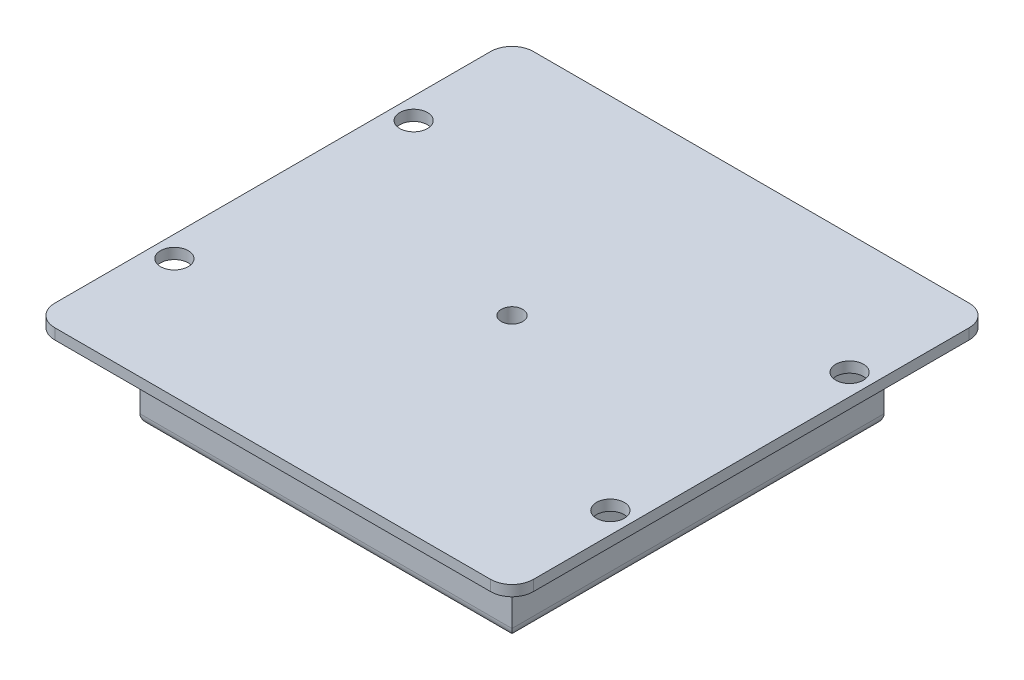
from build123d import *

# Parameters (mm, degrees)
SKETCH1_W                   = 114.3
SKETCH1_H                   = 114.3
BOSS_EXTRUDE1_DEPTH         = 2.54
SKETCH2_W                   = 88.9
SKETCH2_H                   = 88.9
BOSS_EXTRUDE2_DEPTH         = 20.32
G_0_261_DIAMETER_HOLE1_D    = 6.6294
FILLET1_R                   = 2.54
FILLET2_R                   = 5.08
BOSS_EXTRUDE3_DEPTH         = 12.7
SKETCH8_R                   = 3.81
CUT_EXTRUDE1_DEPTH          = 12.7
F_1_4_20_TAPPED_HOLE1_D     = 5.1054
F_1_4_20_TAPPED_HOLE1_DEPTH = 16.51
F_1_4_20_TAPPED_HOLE1_TIP   = 1.533816902


with BuildPart() as part:
    # Sketch1 → Boss-Extrude1 (new body)
    with BuildSketch(Plane(origin=(0, 0, 0), x_dir=(1, 0, 0), z_dir=(0, 1, 0))):
        Rectangle(SKETCH1_W, SKETCH1_H)
    extrude(amount=BOSS_EXTRUDE1_DEPTH)

    # Sketch2 → Boss-Extrude2 (add)
    with BuildSketch(Plane.XZ):
        Rectangle(SKETCH2_W, SKETCH2_H)
    extrude(amount=BOSS_EXTRUDE2_DEPTH)

    # G (0.261) Diameter Hole1 (through all)
    with Locations(Plane(origin=(0, 0, 0), x_dir=(-1, 0, 0), z_dir=(0, -1, 0))):
        with Locations((52.07, -28.575), (52.07, 28.575), (-52.07, -28.575), (-52.07, 28.575)):
            Hole(G_0_261_DIAMETER_HOLE1_D / 2)

    # Fillet1
    fillet1_edges = [part.edges().sort_by_distance(p)[0] for p in [
        (44.45, -20.32, 0),
        (0, -20.32, 44.45),
        (-44.45, -20.32, 0),
        (0, -20.32, -44.45),
    ]]
    fillet(fillet1_edges, radius=FILLET1_R)

    # Fillet2
    fillet2_edges = [part.edges().sort_by_distance(p)[0] for p in [
        (-57.15, 1.27, -57.15),
        (57.15, 1.27, -57.15),
        (57.15, 1.27, 57.15),
        (-57.15, 1.27, 57.15),
    ]]
    fillet(fillet2_edges, radius=FILLET2_R)

    # Sketch5 → Boss-Extrude3 (add)
    with BuildSketch(Plane.ZY.offset(44.45)):
        with BuildLine():
            ThreePointArc((-6.35, -8.89), (0, -15.24), (6.35, -8.89))
            Line((6.35, -8.89), (-6.35, -8.89))
        make_face()
        with BuildLine():
            Line((-6.35, -8.89), (6.35, -8.89))
            ThreePointArc((6.35, -8.89), (0, -2.54), (-6.35, -8.89))
        make_face()
        with BuildLine():
            ThreePointArc((-6.35, -8.89), (0, -2.54), (6.35, -8.89))
            Line((6.35, -8.89), (6.35, 0))
            Line((6.35, 0), (-6.35, 0))
            Line((-6.35, 0), (-6.35, -8.89))
        make_face()
    extrude(amount=BOSS_EXTRUDE3_DEPTH)

    # Sketch8 → Cut-Extrude1 (cut)
    with BuildSketch(Plane.ZY.offset(57.15)):
        with Locations((0, -8.89)):
            Circle(SKETCH8_R)
    extrude(amount=-CUT_EXTRUDE1_DEPTH, mode=Mode.SUBTRACT)

    # 1/4-20 Tapped Hole1
    with Locations(Plane(origin=(0, 2.54, 0), x_dir=(1, 0, 0), z_dir=(0, 1, 0))):
        with Locations((0, 0)):
            Hole(F_1_4_20_TAPPED_HOLE1_D / 2, depth=F_1_4_20_TAPPED_HOLE1_DEPTH)
            with Locations((0, 0, -(F_1_4_20_TAPPED_HOLE1_DEPTH + F_1_4_20_TAPPED_HOLE1_TIP / 2))):  # 118° drill point
                Cone(0, F_1_4_20_TAPPED_HOLE1_D / 2, F_1_4_20_TAPPED_HOLE1_TIP, mode=Mode.SUBTRACT)


solid = part.part
